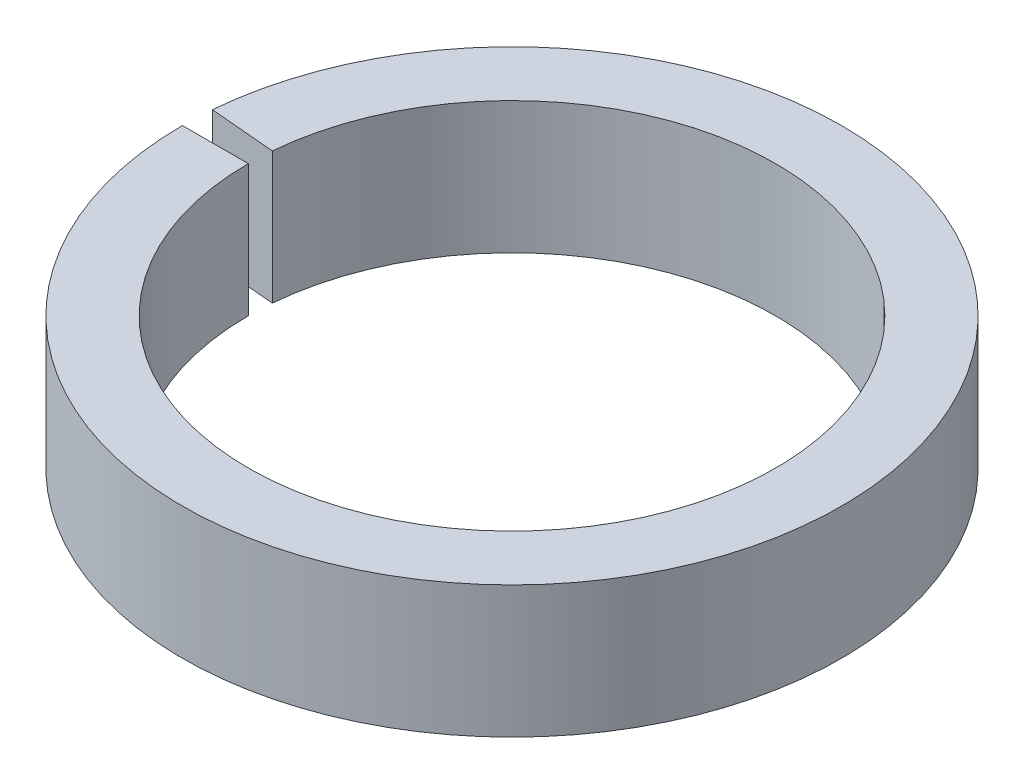
from build123d import *

# Parameters (mm, degrees)
SKETCH1_W      = 1.5875
SKETCH1_H      = 3.175
REVOLVE1_ANGLE = 355


with BuildPart() as part:
    # Sketch1 → Revolve1 (revolve)
    with BuildSketch(Plane.XY):
        with Locations((-7.14375, 1.5875)):
            Rectangle(SKETCH1_W, SKETCH1_H)
    revolve(axis=Axis((0, 0, 0), (0, 1, 0)), revolution_arc=REVOLVE1_ANGLE)


solid = part.part
